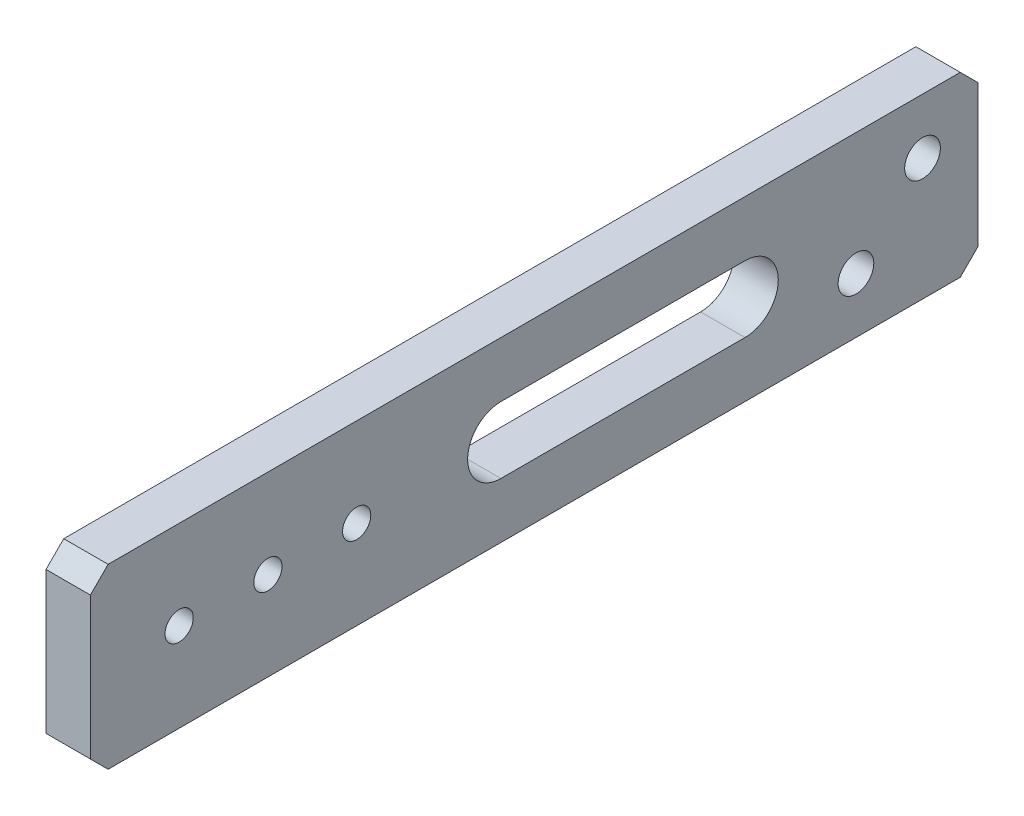
from build123d import *

# Parameters (mm, degrees)
SKETCH1_W              = 127
SKETCH1_H              = 25.4
BOSS_EXTRUDE1_DEPTH    = 6.35
F_10_32_TAPPED_HOLE1_D = 4.0386
F_10_CLEARANCE_HOLE1_D = 5.1054
CHAMFER1_SIZE          = 2.54
CUT_EXTRUDE1_DEPTH     = 7.35


with BuildPart() as part:
    # Sketch1 → Boss-Extrude1 (new body)
    with BuildSketch(Plane(origin=(0, 0, 0), x_dir=(0, 0, -1), z_dir=(1, 0, 0))):
        with Locations((63.5, 12.7)):
            Rectangle(SKETCH1_W, SKETCH1_H)
    extrude(amount=BOSS_EXTRUDE1_DEPTH)

    # #10-32 Tapped Hole1 (through all)
    with Locations(Plane(origin=(6.35, 0, 0), x_dir=(0, 0, -1), z_dir=(1, 0, 0))):
        with Locations((12.7, 12.7), (25.4, 12.7), (38.1, 12.7)):
            Hole(F_10_32_TAPPED_HOLE1_D / 2)

    # #10 Clearance Hole1 (through all)
    with Locations(Plane(origin=(6.35, 0, 0), x_dir=(0, 0, -1), z_dir=(1, 0, 0))):
        with Locations((119.0625, 17.4625), (109.5375, 7.9375)):
            Hole(F_10_CLEARANCE_HOLE1_D / 2)

    # Chamfer1
    chamfer1_edges = [part.edges().sort_by_distance(p)[0] for p in [
        (3.175, 25.4, 0),
        (3.175, 25.4, -127),
        (3.175, 0, -127),
        (3.175, 0, 0),
    ]]
    chamfer(chamfer1_edges, length=CHAMFER1_SIZE)

    # Sketch6 → Cut-Extrude1 (cut, through all)
    with BuildSketch(Plane(origin=(6.35, 0, 0), x_dir=(0, 0, -1), z_dir=(1, 0, 0))):
        with BuildLine():
            Line((93.6625, 7.9375), (58.7375, 7.9375))
            ThreePointArc((58.7375, 7.9375), (53.975, 12.7), (58.7375, 17.4625))
            Line((58.7375, 17.4625), (93.6625, 17.4625))
            ThreePointArc((93.6625, 17.4625), (98.425, 12.7), (93.6625, 7.9375))
        make_face()
    extrude(amount=-CUT_EXTRUDE1_DEPTH, mode=Mode.SUBTRACT)


solid = part.part
